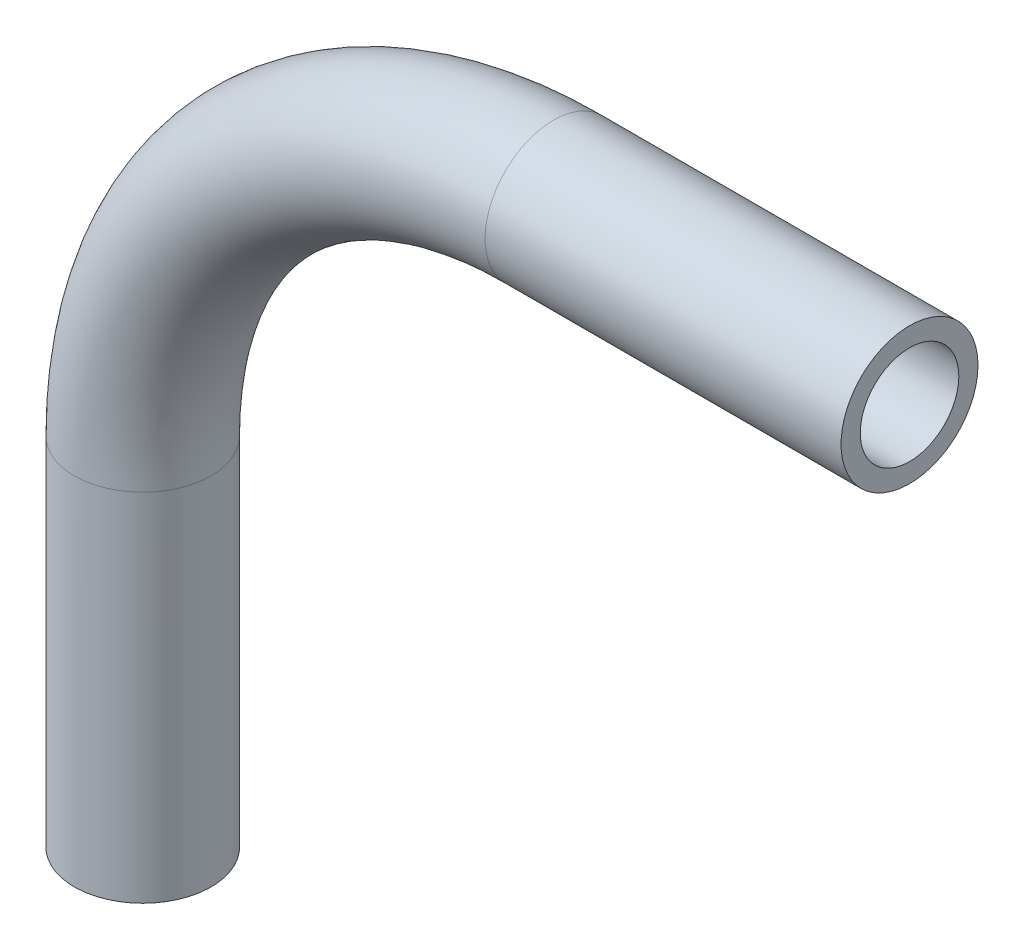
from build123d import *

# Parameters (mm, degrees)
SKETCH2_R   = 3.175
SKETCH2_R_2 = 2.286


with BuildPart() as part:
    # Sweep1: sweep along a path in Sketch1
    with BuildLine(Plane.XY) as sweep1_path:
        Line((0, -18.032317881), (0, -1.522317881))
        ThreePointArc((0, -1.522317881), (5.579615818, 11.948066301), (19.05, 17.527682119))
        Line((19.05, 17.527682119), (35.56, 17.527682119))
    # Sketch2 → Sweep1 (sweep)
    with BuildSketch(Plane(origin=(35.56, 17.527682119, 0), x_dir=(0, 0, -1), z_dir=(1, 0, 0))):
        Circle(SKETCH2_R)
        Circle(SKETCH2_R_2, mode=Mode.SUBTRACT)
    sweep(path=sweep1_path.line)


solid = part.part
